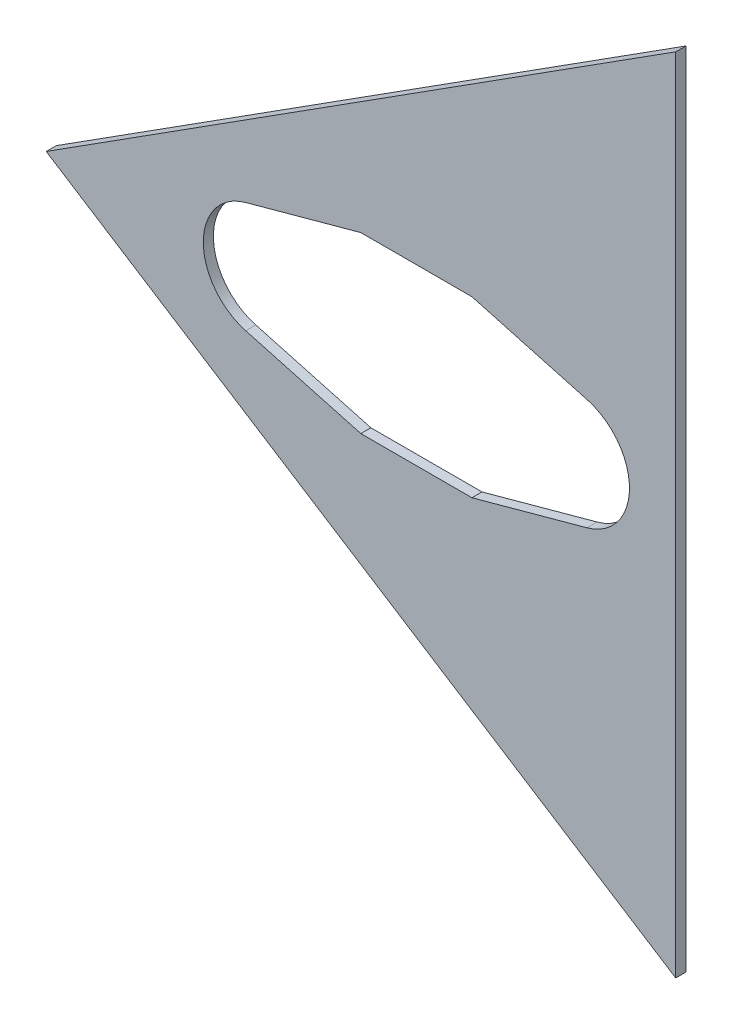
from build123d import *

# Parameters (mm, degrees)
BOSS_EXTRUDE1_DEPTH = 6.35
CUT_EXTRUDE1_DEPTH  = 7.35
SKETCH3_OUTSIDE_W   = 609.496
SKETCH3_OUTSIDE_H   = 769.968
CUT_EXTRUDE6_DEPTH  = 7.35


with BuildPart() as part:
    # Sketch1 → Boss-Extrude1 (new body)
    with BuildSketch(Plane.XY):
        Polygon((228.232926514, 307.505861177), (-209.583790114, 0.94329584), (-209.583790114, -0.94329584), (228.232926514, -307.505861177), (244.956408235, -271.642238892), (244.956408235, 271.642238892), align=None)
    extrude(amount=BOSS_EXTRUDE1_DEPTH)

    # Sketch2 → Cut-Extrude1 (cut, through all)
    with BuildSketch(Plane(origin=(0, 0, 0), x_dir=(-1, 0, 0), z_dir=(0, 0, -1))):
        with BuildLine():
            Line((-46.185656441, -54.927437645), (26.505438481, -35.03371061))
            ThreePointArc((26.505438481, -35.03371061), (53.239591757, 0), (26.505438481, 35.03371061))
            Line((26.505438481, 35.03371061), (-46.185656445, 54.927437638))
            Line((-46.185656445, 54.927437638), (-116.321160011, 54.927437643))
            Line((-116.321160011, 54.927437643), (-189.012254957, 35.03371061))
            ThreePointArc((-189.012254957, 35.03371061), (-215.746408235, 1e-09), (-189.012254959, -35.033710609))
            Line((-189.012254959, -35.033710609), (-116.32116001, -54.927437641))
            Line((-116.32116001, -54.927437641), (-46.185656441, -54.927437645))
        make_face()
    extrude(amount=-CUT_EXTRUDE1_DEPTH, mode=Mode.SUBTRACT)

    # Sketch3 outside → Cut-Extrude6 (cut, through all)
    with BuildSketch(Plane.XY):
        with Locations((17.686, 0)):
            Rectangle(SKETCH3_OUTSIDE_W, SKETCH3_OUTSIDE_H)
        Polygon((244.956408235, -253.143950628), (-152.4, 0), (244.956408235, 253.143950628), align=None, mode=Mode.SUBTRACT)
    extrude(amount=CUT_EXTRUDE6_DEPTH, mode=Mode.SUBTRACT)


solid = part.part
